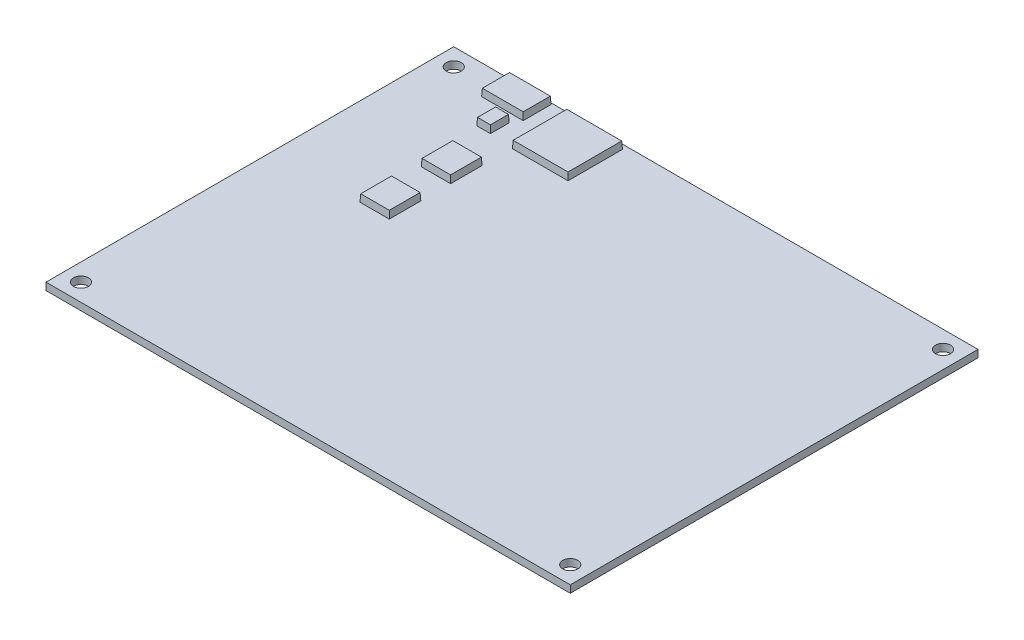
from build123d import *

# Parameters (mm, degrees)
EXTRUDE1_DEPTH        = 1.6002
F_4_CLEARANCE_HOLE1_D = 3.2639
SKETCH5_W             = 6.392759032
SKETCH5_H             = 6.880194124
SKETCH5_W_2           = 9.067841131
SKETCH5_H_2           = 6.084228887
SKETCH5_H_3           = 6.880194125
SKETCH5_W_3           = 12.126342144
SKETCH5_H_4           = 11.868334865
SKETCH5_W_4           = 2.983612243
SKETCH5_H_5           = 4.095154059
BOSS_EXTRUDE1_DEPTH   = 1.5875
BOSS_EXTRUDE1_TAPER   = 3


with BuildPart() as part:
    # Sketch1 → Extrude1 (new body)
    with BuildSketch(Plane(origin=(0, 0, 0), x_dir=(1, 0, 0), z_dir=(0, 1, 0))):
        Polygon((-55.88, -44.45), (49.53, -44.45), (57.15, -44.45), (57.15, -6.35), (57.15, 44.45), (-57.15, 44.45), (-57.15, -6.35), (-57.15, -44.45), align=None)
    extrude(amount=EXTRUDE1_DEPTH)

    # #4 Clearance Hole1 (through all)
    with Locations(Plane(origin=(0, 1.6002, 0), x_dir=(-1, 0, 0), z_dir=(0, 1, 0))):
        with Locations((53.34, -40.64), (-53.34, -40.64), (-53.34, 40.64), (53.34, 40.64)):
            Hole(F_4_CLEARANCE_HOLE1_D / 2)

    # Sketch5 → Boss-Extrude1 (add)
    with BuildSketch(Plane(origin=(0, 1.6002, 0), x_dir=(1, 0, 0), z_dir=(0, 1, 0))):
        with Locations((-34.824290025, 21.681433757)):
            Rectangle(SKETCH5_W, SKETCH5_H)
        with Locations((-40.158796151, 41.104015903)):
            Rectangle(SKETCH5_W_2, SKETCH5_H_2)
        with Locations((-34.824290025, 8.310130462)):
            Rectangle(SKETCH5_W, SKETCH5_H_3)
        with Locations((-25.440323861, 37.525712701)):
            Rectangle(SKETCH5_W_3, SKETCH5_H_4)
        with Locations((-38.228223524, 34.083751803)):
            Rectangle(SKETCH5_W_4, SKETCH5_H_5)
    extrude(amount=BOSS_EXTRUDE1_DEPTH, taper=BOSS_EXTRUDE1_TAPER)


solid = part.part
